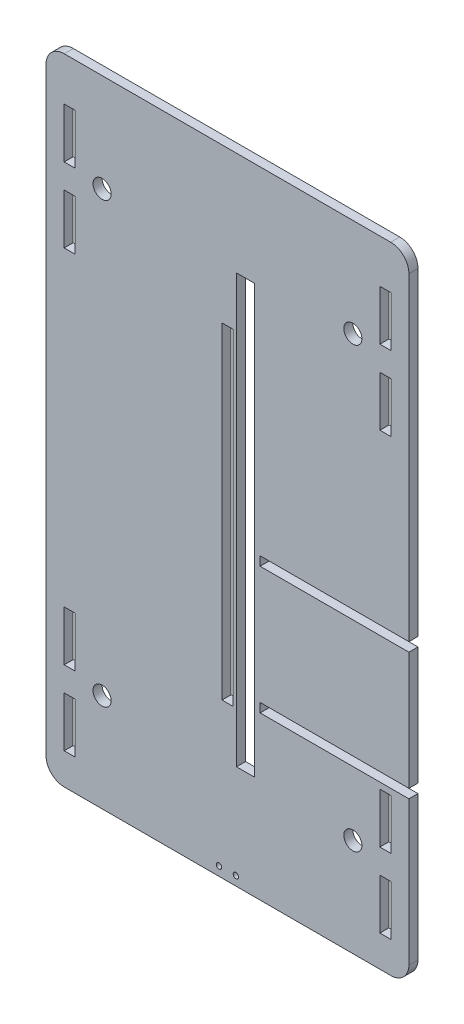
from build123d import *

# Parameters (mm, degrees)
SKETCH1_R           = 5
BOSS_EXTRUDE1_DEPTH = 5
SKETCH4_W           = 6
SKETCH4_H           = 180
SKETCH4_W_2         = 10
SKETCH4_H_2         = 235.736115182
SKETCH4_W_3         = 82
SKETCH4_H_3         = 5
CUT_EXTRUDE1_DEPTH  = 10
SKETCH5_R           = 1.5
SKETCH5_W           = 6
SKETCH5_H           = 27.65
CUT_EXTRUDE2_DEPTH  = 6
FILLET1_R           = 10


with BuildPart() as part:
    # Sketch1 → Boss-Extrude1 (new body)
    with BuildSketch(Plane.XY):
        Polygon((100, 190), (-100, 190), (-100, -90), (-100, -160), (100, -160), (100, -90), align=None)
        with Locations((-69.105066414, 135.933866224)):
            Circle(SKETCH1_R, mode=Mode.SUBTRACT)
        with Locations((69.105066414, 135.933866224)):
            Circle(SKETCH1_R, mode=Mode.SUBTRACT)
        with Locations((69.105066414, -105.933866224)):
            Circle(SKETCH1_R, mode=Mode.SUBTRACT)
        with Locations((-69.105066414, -105.933866224)):
            Circle(SKETCH1_R, mode=Mode.SUBTRACT)
    extrude(amount=BOSS_EXTRUDE1_DEPTH)

    # Sketch4 → Cut-Extrude1 (cut)
    with BuildSketch(Plane.XY.offset(5)):
        with Locations((0, 15)):
            Rectangle(SKETCH4_W, SKETCH4_H)
        with Locations((10, 15)):
            Rectangle(SKETCH4_W_2, SKETCH4_H_2)
        with Locations((59, -68.15)):
            Rectangle(SKETCH4_W_3, SKETCH4_H_3)
        with Locations((59, 1.85)):
            Rectangle(SKETCH4_W_3, SKETCH4_H_3)
    extrude(amount=-CUT_EXTRUDE1_DEPTH, mode=Mode.SUBTRACT)

    # Sketch5 → Cut-Extrude2 (cut, through all)
    with BuildSketch(Plane.XY.offset(5)):
        with Locations((4.67, -155)):
            Circle(SKETCH5_R)
        with Locations((-4.67, -155)):
            Circle(SKETCH5_R)
        with Locations((-87, 152.175)):
            Rectangle(SKETCH5_W, SKETCH5_H)
        with Locations((-87, 111.115)):
            Rectangle(SKETCH5_W, SKETCH5_H)
        with Locations((-87, -87.845)):
            Rectangle(SKETCH5_W, SKETCH5_H)
        with Locations((-87, -128.905)):
            Rectangle(SKETCH5_W, SKETCH5_H)
        with Locations((87, -87.845)):
            Rectangle(SKETCH5_W, SKETCH5_H)
        with Locations((87, -128.905)):
            Rectangle(SKETCH5_W, SKETCH5_H)
        with Locations((87, 152.175)):
            Rectangle(SKETCH5_W, SKETCH5_H)
        with Locations((87, 111.115)):
            Rectangle(SKETCH5_W, SKETCH5_H)
    extrude(amount=-CUT_EXTRUDE2_DEPTH, mode=Mode.SUBTRACT)

    # Fillet1
    fillet1_edges = [part.edges().sort_by_distance(p)[0] for p in [
        (-100, 190, 2.5),
        (100, 190, 2.5),
        (100, -160, 2.5),
        (-100, -160, 2.5),
    ]]
    fillet(fillet1_edges, radius=FILLET1_R)


solid = part.part
